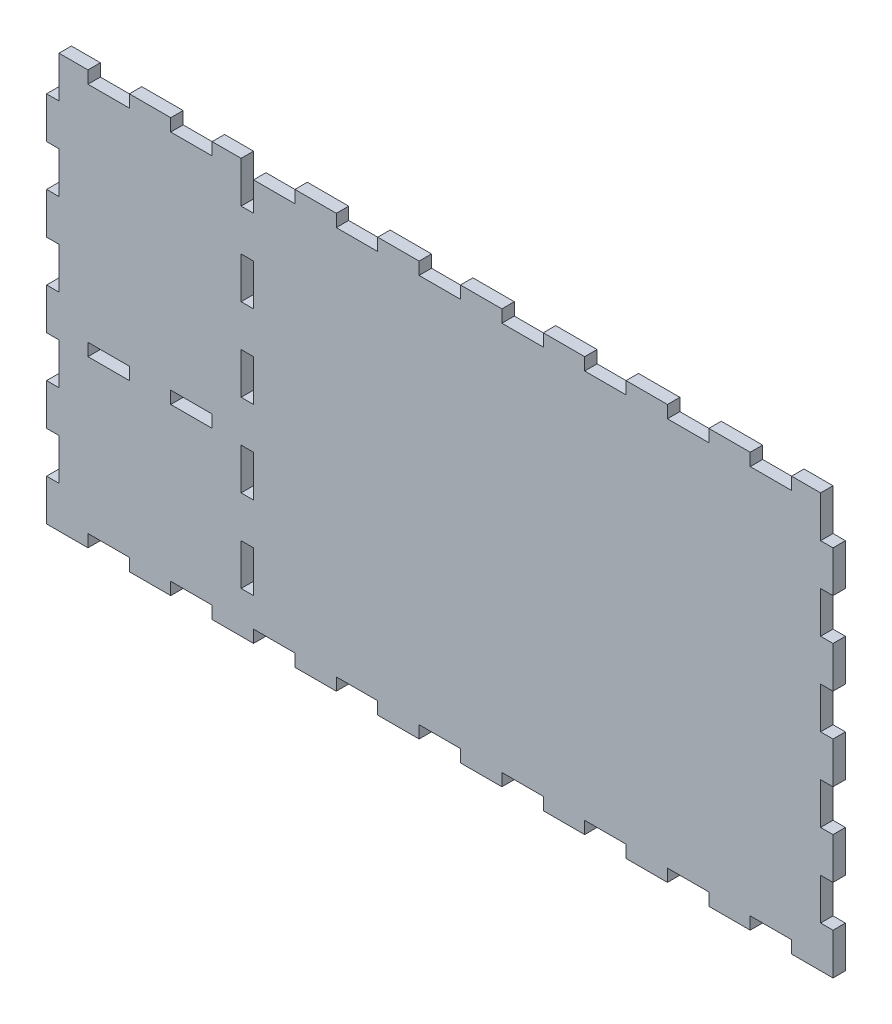
from build123d import *

# Parameters (mm, degrees)
SKETCH1_W               = 380
SKETCH1_H               = 200
BOSS_EXTRUDE1_DEPTH     = 6
SKETCH6_W               = 6
SKETCH6_H               = 20
CUT_EXTRUDE4_DEPTH      = 7
LPATTERN3_COUNT         = 5
LPATTERN3_PITCH         = 40
SKETCH7_W               = 20
SKETCH7_H               = 6
CUT_EXTRUDE5_DEPTH      = 10
LPATTERN4_COUNT         = 9
LPATTERN4_PITCH         = 40
MIRROR1_COPY_1_SKETCH_W = 20
MIRROR1_COPY_1_SKETCH_H = 6
MIRROR1_COPY_1_DEPTH    = 10
MIRROR1_COPY_2_SKETCH_W = 20
MIRROR1_COPY_2_SKETCH_H = 6
MIRROR1_COPY_2_DEPTH    = 10
MIRROR1_COPY_3_SKETCH_W = 20
MIRROR1_COPY_3_SKETCH_H = 6
MIRROR1_COPY_3_DEPTH    = 10
MIRROR1_COPY_4_SKETCH_W = 20
MIRROR1_COPY_4_SKETCH_H = 6
MIRROR1_COPY_4_DEPTH    = 10
MIRROR1_COPY_5_SKETCH_W = 20
MIRROR1_COPY_5_SKETCH_H = 6
MIRROR1_COPY_5_DEPTH    = 10
MIRROR1_COPY_6_SKETCH_W = 20
MIRROR1_COPY_6_SKETCH_H = 6
MIRROR1_COPY_6_DEPTH    = 10
MIRROR1_COPY_7_SKETCH_W = 20
MIRROR1_COPY_7_SKETCH_H = 6
MIRROR1_COPY_7_DEPTH    = 10
MIRROR1_COPY_8_SKETCH_W = 20
MIRROR1_COPY_8_SKETCH_H = 6
MIRROR1_COPY_8_DEPTH    = 10
MIRROR2_COPY_1_SKETCH_W = 6
MIRROR2_COPY_1_SKETCH_H = 20
MIRROR2_COPY_1_DEPTH    = 7
MIRROR2_COPY_2_SKETCH_W = 6
MIRROR2_COPY_2_SKETCH_H = 20
MIRROR2_COPY_2_DEPTH    = 7
MIRROR2_COPY_3_SKETCH_W = 6
MIRROR2_COPY_3_SKETCH_H = 20
MIRROR2_COPY_3_DEPTH    = 7
MIRROR2_COPY_4_SKETCH_W = 6
MIRROR2_COPY_4_SKETCH_H = 20
MIRROR2_COPY_4_DEPTH    = 7
SKETCH10_W              = 6
SKETCH10_H              = 20
CUT_EXTRUDE6_DEPTH      = 10
LPATTERN5_COUNT         = 5
LPATTERN5_PITCH         = 40
SKETCH11_W              = 20
SKETCH11_H              = 6
CUT_EXTRUDE7_DEPTH      = 10
LPATTERN6_COUNT         = 2
LPATTERN6_PITCH         = 40


with BuildPart() as part:
    # Sketch1 → Boss-Extrude1 (new body)
    with BuildSketch(Plane.XY):
        with Locations((77.096774194, -21.774193548)):
            Rectangle(SKETCH1_W, SKETCH1_H)
    extrude(amount=BOSS_EXTRUDE1_DEPTH)

    # Sketch6 → Cut-Extrude4 (cut, through all)
    with BuildSketch(Plane.XY):
        with Locations((-109.903225806, 68.225806452)):
            Rectangle(SKETCH6_W, SKETCH6_H)
    cut_extrude4 = extrude(amount=CUT_EXTRUDE4_DEPTH, mode=Mode.SUBTRACT)

    # LPattern3: Cut-Extrude4 ×5
    with Locations(*[(0, -i * LPATTERN3_PITCH, 0) for i in range(1, LPATTERN3_COUNT)]):
        add(cut_extrude4, mode=Mode.SUBTRACT)

    # Sketch7 → Cut-Extrude5 (cut)
    with BuildSketch(Plane.XY.offset(6)):
        with Locations((-82.903225806, 75.225806452)):
            Rectangle(SKETCH7_W, SKETCH7_H)
    cut_extrude5 = extrude(amount=-CUT_EXTRUDE5_DEPTH, mode=Mode.SUBTRACT)

    # LPattern4: Cut-Extrude5 ×9
    with Locations(*[(i * LPATTERN4_PITCH, 0, 0) for i in range(1, LPATTERN4_COUNT)]):
        add(cut_extrude5, mode=Mode.SUBTRACT)

    # Mirror1: Cut-Extrude5 across plane
    add(cut_extrude5.mirror(Plane.ZX.offset(-21.774193548)), mode=Mode.SUBTRACT)

    # Mirror1 copy 1 sketch → Mirror1 copy 1 (cut)
    with BuildSketch(Plane(origin=(40, -43.548387097, 6), x_dir=(1, 0, 0), z_dir=(0, 0, 1))):
        with Locations((-82.903225806, -75.225806452)):
            Rectangle(MIRROR1_COPY_1_SKETCH_W, MIRROR1_COPY_1_SKETCH_H)
    extrude(amount=-MIRROR1_COPY_1_DEPTH, mode=Mode.SUBTRACT)

    # Mirror1 copy 2 sketch → Mirror1 copy 2 (cut)
    with BuildSketch(Plane(origin=(80, -43.548387097, 6), x_dir=(1, 0, 0), z_dir=(0, 0, 1))):
        with Locations((-82.903225806, -75.225806452)):
            Rectangle(MIRROR1_COPY_2_SKETCH_W, MIRROR1_COPY_2_SKETCH_H)
    extrude(amount=-MIRROR1_COPY_2_DEPTH, mode=Mode.SUBTRACT)

    # Mirror1 copy 3 sketch → Mirror1 copy 3 (cut)
    with BuildSketch(Plane(origin=(120, -43.548387097, 6), x_dir=(1, 0, 0), z_dir=(0, 0, 1))):
        with Locations((-82.903225806, -75.225806452)):
            Rectangle(MIRROR1_COPY_3_SKETCH_W, MIRROR1_COPY_3_SKETCH_H)
    extrude(amount=-MIRROR1_COPY_3_DEPTH, mode=Mode.SUBTRACT)

    # Mirror1 copy 4 sketch → Mirror1 copy 4 (cut)
    with BuildSketch(Plane(origin=(160, -43.548387097, 6), x_dir=(1, 0, 0), z_dir=(0, 0, 1))):
        with Locations((-82.903225806, -75.225806452)):
            Rectangle(MIRROR1_COPY_4_SKETCH_W, MIRROR1_COPY_4_SKETCH_H)
    extrude(amount=-MIRROR1_COPY_4_DEPTH, mode=Mode.SUBTRACT)

    # Mirror1 copy 5 sketch → Mirror1 copy 5 (cut)
    with BuildSketch(Plane(origin=(200, -43.548387097, 6), x_dir=(1, 0, 0), z_dir=(0, 0, 1))):
        with Locations((-82.903225806, -75.225806452)):
            Rectangle(MIRROR1_COPY_5_SKETCH_W, MIRROR1_COPY_5_SKETCH_H)
    extrude(amount=-MIRROR1_COPY_5_DEPTH, mode=Mode.SUBTRACT)

    # Mirror1 copy 6 sketch → Mirror1 copy 6 (cut)
    with BuildSketch(Plane(origin=(240, -43.548387097, 6), x_dir=(1, 0, 0), z_dir=(0, 0, 1))):
        with Locations((-82.903225806, -75.225806452)):
            Rectangle(MIRROR1_COPY_6_SKETCH_W, MIRROR1_COPY_6_SKETCH_H)
    extrude(amount=-MIRROR1_COPY_6_DEPTH, mode=Mode.SUBTRACT)

    # Mirror1 copy 7 sketch → Mirror1 copy 7 (cut)
    with BuildSketch(Plane(origin=(280, -43.548387097, 6), x_dir=(1, 0, 0), z_dir=(0, 0, 1))):
        with Locations((-82.903225806, -75.225806452)):
            Rectangle(MIRROR1_COPY_7_SKETCH_W, MIRROR1_COPY_7_SKETCH_H)
    extrude(amount=-MIRROR1_COPY_7_DEPTH, mode=Mode.SUBTRACT)

    # Mirror1 copy 8 sketch → Mirror1 copy 8 (cut)
    with BuildSketch(Plane(origin=(320, -43.548387097, 6), x_dir=(1, 0, 0), z_dir=(0, 0, 1))):
        with Locations((-82.903225806, -75.225806452)):
            Rectangle(MIRROR1_COPY_8_SKETCH_W, MIRROR1_COPY_8_SKETCH_H)
    extrude(amount=-MIRROR1_COPY_8_DEPTH, mode=Mode.SUBTRACT)

    # Mirror2: Cut-Extrude4 across plane
    add(cut_extrude4.mirror(Plane(origin=(77.096774194, 0, 0), x_dir=(0, 0, 1), z_dir=(1, 0, 0))), mode=Mode.SUBTRACT)

    # Mirror2 copy 1 sketch → Mirror2 copy 1 (cut, through all)
    with BuildSketch(Plane(origin=(154.193548387, -40, 0), x_dir=(-1, 0, 0), z_dir=(0, 0, 1))):
        with Locations((-109.903225806, -68.225806452)):
            Rectangle(MIRROR2_COPY_1_SKETCH_W, MIRROR2_COPY_1_SKETCH_H)
    extrude(amount=MIRROR2_COPY_1_DEPTH, mode=Mode.SUBTRACT)

    # Mirror2 copy 2 sketch → Mirror2 copy 2 (cut, through all)
    with BuildSketch(Plane(origin=(154.193548387, -80, 0), x_dir=(-1, 0, 0), z_dir=(0, 0, 1))):
        with Locations((-109.903225806, -68.225806452)):
            Rectangle(MIRROR2_COPY_2_SKETCH_W, MIRROR2_COPY_2_SKETCH_H)
    extrude(amount=MIRROR2_COPY_2_DEPTH, mode=Mode.SUBTRACT)

    # Mirror2 copy 3 sketch → Mirror2 copy 3 (cut, through all)
    with BuildSketch(Plane(origin=(154.193548387, -120, 0), x_dir=(-1, 0, 0), z_dir=(0, 0, 1))):
        with Locations((-109.903225806, -68.225806452)):
            Rectangle(MIRROR2_COPY_3_SKETCH_W, MIRROR2_COPY_3_SKETCH_H)
    extrude(amount=MIRROR2_COPY_3_DEPTH, mode=Mode.SUBTRACT)

    # Mirror2 copy 4 sketch → Mirror2 copy 4 (cut, through all)
    with BuildSketch(Plane(origin=(154.193548387, -160, 0), x_dir=(-1, 0, 0), z_dir=(0, 0, 1))):
        with Locations((-109.903225806, -68.225806452)):
            Rectangle(MIRROR2_COPY_4_SKETCH_W, MIRROR2_COPY_4_SKETCH_H)
    extrude(amount=MIRROR2_COPY_4_DEPTH, mode=Mode.SUBTRACT)

    # Sketch10 → Cut-Extrude6 (cut)
    with BuildSketch(Plane(origin=(0, 0, 0), x_dir=(-1, 0, 0), z_dir=(0, 0, -1))):
        with Locations((15.903225806, 68.225806452)):
            Rectangle(SKETCH10_W, SKETCH10_H)
    cut_extrude6 = extrude(amount=-CUT_EXTRUDE6_DEPTH, mode=Mode.SUBTRACT)

    # LPattern5: Cut-Extrude6 ×5
    with Locations(*[(0, -i * LPATTERN5_PITCH, 0) for i in range(1, LPATTERN5_COUNT)]):
        add(cut_extrude6, mode=Mode.SUBTRACT)

    # Sketch11 → Cut-Extrude7 (cut)
    with BuildSketch(Plane(origin=(0, 0, 0), x_dir=(-1, 0, 0), z_dir=(0, 0, -1))):
        with Locations((42.903225806, -38.774193548)):
            Rectangle(SKETCH11_W, SKETCH11_H)
    cut_extrude7 = extrude(amount=-CUT_EXTRUDE7_DEPTH, mode=Mode.SUBTRACT)

    # LPattern6: Cut-Extrude7 ×2
    with Locations(*[(-i * LPATTERN6_PITCH, 0, 0) for i in range(1, LPATTERN6_COUNT)]):
        add(cut_extrude7, mode=Mode.SUBTRACT)


solid = part.part
